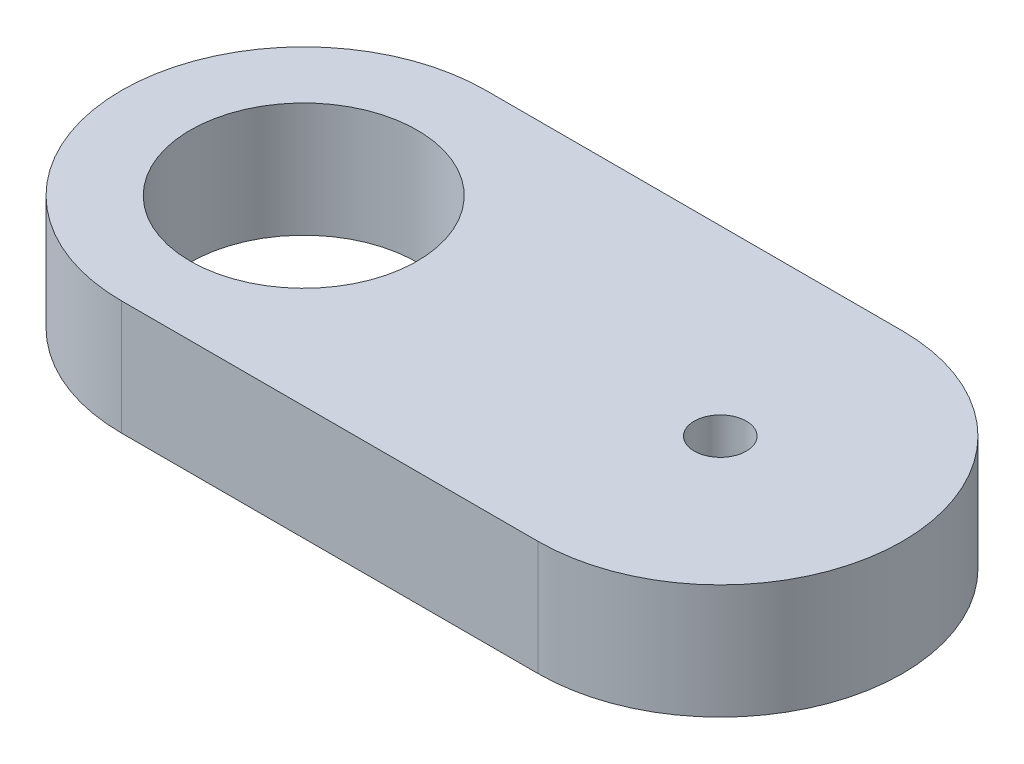
from build123d import *

# Parameters (mm, degrees)
SKETCH1_R               = 2
SKETCH1_R_2             = 2.5
BOSS_EXTRUDE1_DEPTH     = 11
CUT_EXTRUDE1_REACH      = 22.585
CUT_EXTRUDE1_END_RADIUS = 2.5
SKETCH2_R               = 1.5
BOSS_EXTRUDE2_DEPTH     = 11
SKETCH4_R               = 10.9
CUT_EXTRUDE2_DEPTH      = 37.710978084


with BuildPart() as part:
    # Sketch1 → Boss-Extrude1 (new body)
    with BuildSketch(Plane(origin=(0, 0, 0), x_dir=(1, 0, 0), z_dir=(0, 1, 0))):
        with BuildLine():
            Line((-1.245136187, 9.922178988), (-40, 7.5))
            ThreePointArc((-40, 7.5), (-47.5, 0), (-40, -7.5))
            Line((-40, -7.5), (-1.245136187, -9.922178988))
            Line((-1.245136187, -9.922178988), (0, -10))
            ThreePointArc((0, -10), (10, 0), (0, 10))
            Line((0, 10), (-1.245136187, 9.922178988))
        make_face()
        with Locations(Location((-40, 0, 0), (0, 0, 270))):  # turned: the seam where the file's is
            Circle(SKETCH1_R, mode=Mode.SUBTRACT)
        with Locations(Location((0, 0, 0), (0, 0, 270))):  # turned: the seam where the file's is
            Circle(SKETCH1_R_2, mode=Mode.SUBTRACT)
    extrude(amount=BOSS_EXTRUDE1_DEPTH)

    # Cut-Extrude1: up to this cylinder (the profile starts outside it)
    cut_extrude1_end = Plane(origin=(0, 6.089956, 0), z_dir=(0, -1, 0)) * Cylinder(CUT_EXTRUDE1_END_RADIUS, 51.17, mode=Mode.PRIVATE)
    # Sketch2 → Cut-Extrude1 (cut, up to the surface)
    with BuildSketch(Plane(origin=(-0.622568093, 0, -9.961089494), x_dir=(-0.998052578, 0, 0.062378286), z_dir=(-0.062378286, 0, -0.998052578)), mode=Mode.PRIVATE) as cut_extrude1_sk1:
        with Locations(Location((0, 6.089956485, 0), (0, 0, 95.967470529))):  # turned: the seam where the file's is
            Circle(SKETCH2_R)
    cut_extrude1_tool1 = extrude(cut_extrude1_sk1.sketch, amount=-CUT_EXTRUDE1_REACH, mode=Mode.PRIVATE) - cut_extrude1_end
    add(cut_extrude1_tool1.solids().sort_by_distance((-0.622568, 6.089956, -9.961089))[0], mode=Mode.SUBTRACT)

    # Sketch3 → Boss-Extrude2 (add)
    with BuildSketch(Plane(origin=(0, 11, 0), x_dir=(1, 0, 0), z_dir=(0, 1, 0))):
        with BuildLine():
            Line((0, -17.5), (-40, -17.5))
            ThreePointArc((-40, -17.5), (-57.5, 0), (-40, 17.5))
            Line((-40, 17.5), (0, 17.5))
            ThreePointArc((0, 17.5), (17.5, 0), (0, -17.5))
        make_face()
        with BuildLine():
            Line((0, 10), (-40, 7.5))
            ThreePointArc((-40, 7.5), (-47.5, 0), (-40, -7.5))
            Line((-40, -7.5), (0, -10))
            ThreePointArc((0, -10), (10, 0), (0, 10))
        make_face(mode=Mode.SUBTRACT)
    extrude(amount=-BOSS_EXTRUDE2_DEPTH)

    # Sketch4 → Cut-Extrude2 (cut)
    with BuildSketch(Plane(origin=(0, 11, 0), x_dir=(1, 0, 0), z_dir=(0, 1, 0))):
        with Locations(Location((-40, 0, 0), (0, 0, 270))):  # turned: the seam where the file's is
            Circle(SKETCH4_R)
    extrude(amount=-CUT_EXTRUDE2_DEPTH, mode=Mode.SUBTRACT)


solid = part.part
